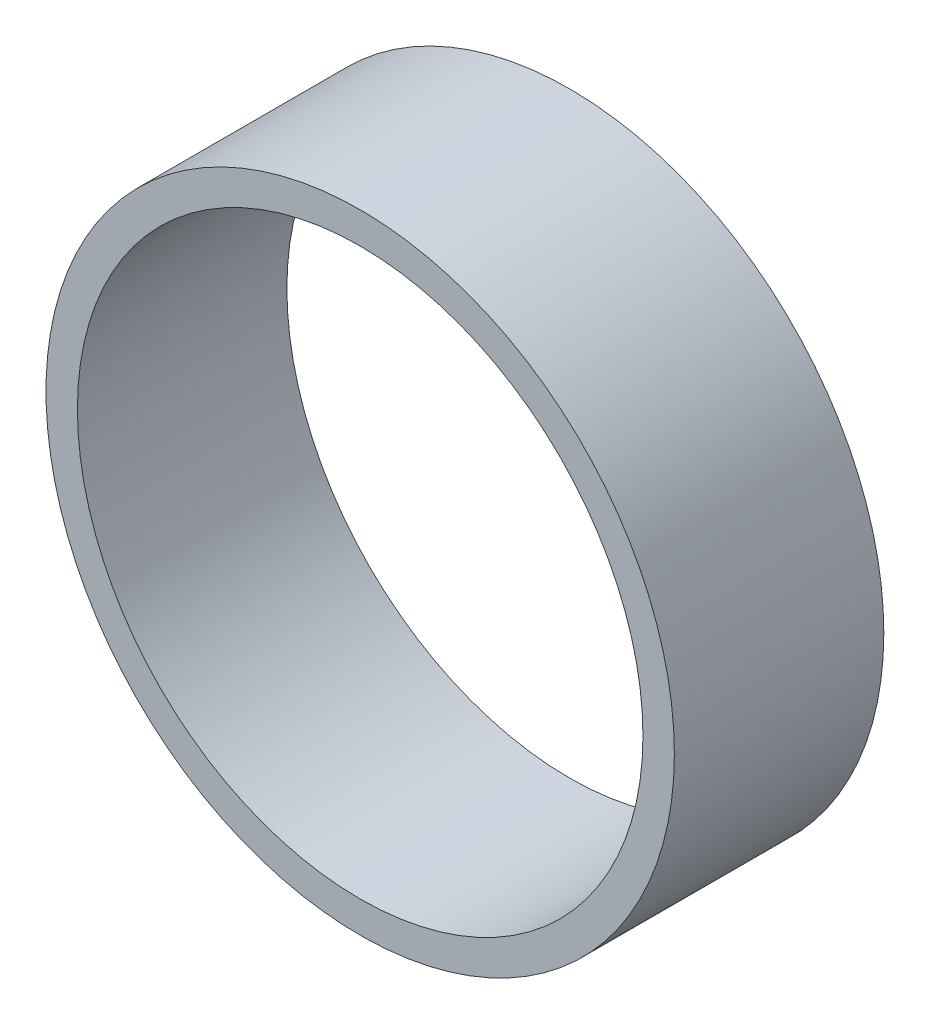
from build123d import *

# Parameters (mm, degrees)
SZKIC2_R                    = 30
SZKIC2_R_2                  = 27
DODANIE_WYCI_GNI_CIE1_DEPTH = 20


with BuildPart() as part:
    # Szkic2 → Dodanie-wyciągnięcie1 (new body)
    with BuildSketch(Plane.XY):
        Circle(SZKIC2_R)
        Circle(SZKIC2_R_2, mode=Mode.SUBTRACT)
    extrude(amount=DODANIE_WYCI_GNI_CIE1_DEPTH)


solid = part.part
